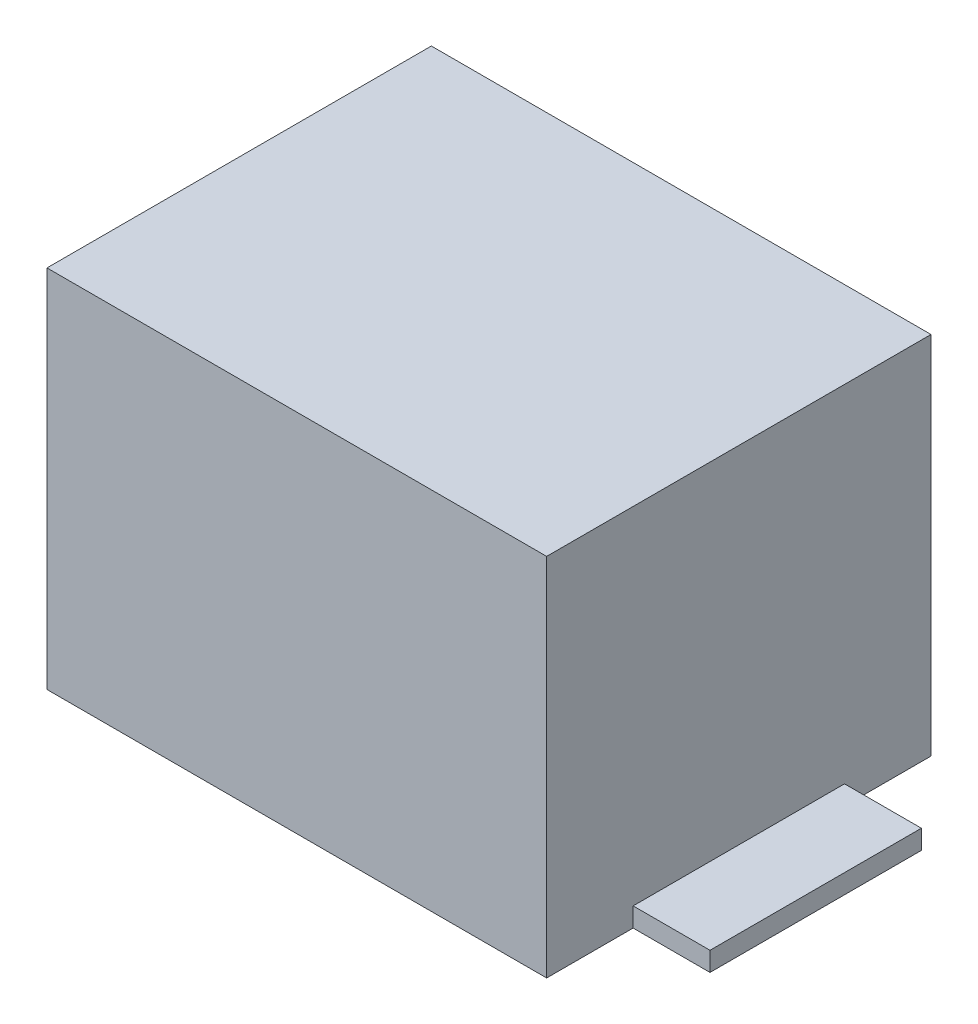
from build123d import *

# Parameters (mm, degrees)
SKIZZE1_W                         = 26
SKIZZE1_H                         = 20
AUFSATZ_LINEAR_AUSTRAGEN1_DEPTH   = 19
SKIZZE2_W                         = 4
SKIZZE2_H                         = 11
AUFSATZ_LINEAR_AUSTRAGEN2_DEPTH   = 1
AUFSATZ_LINEAR_AUSTRAGEN2_2_DEPTH = 1


with BuildPart() as part:
    # Skizze1 → Aufsatz-Linear austragen1 (new body)
    with BuildSketch(Plane(origin=(0, 0, 0), x_dir=(1, 0, 0), z_dir=(0, 1, 0))):
        Rectangle(SKIZZE1_W, SKIZZE1_H)
    extrude(amount=AUFSATZ_LINEAR_AUSTRAGEN1_DEPTH)


with BuildPart() as body_2:
    # Skizze2 → Aufsatz-Linear austragen2 (new body)
    with BuildSketch(Plane.XZ):
        with Locations((-15, 0)):
            Rectangle(SKIZZE2_W, SKIZZE2_H)
    extrude(amount=-AUFSATZ_LINEAR_AUSTRAGEN2_DEPTH)


with BuildPart() as body_3:
    # Skizze2 → Aufsatz-Linear austragen2 2 (new body)
    with BuildSketch(Plane.XZ):
        with Locations((15, 0)):
            Rectangle(SKIZZE2_W, SKIZZE2_H)
    extrude(amount=-AUFSATZ_LINEAR_AUSTRAGEN2_2_DEPTH)


solid = Compound([part.part, body_2.part, body_3.part])
